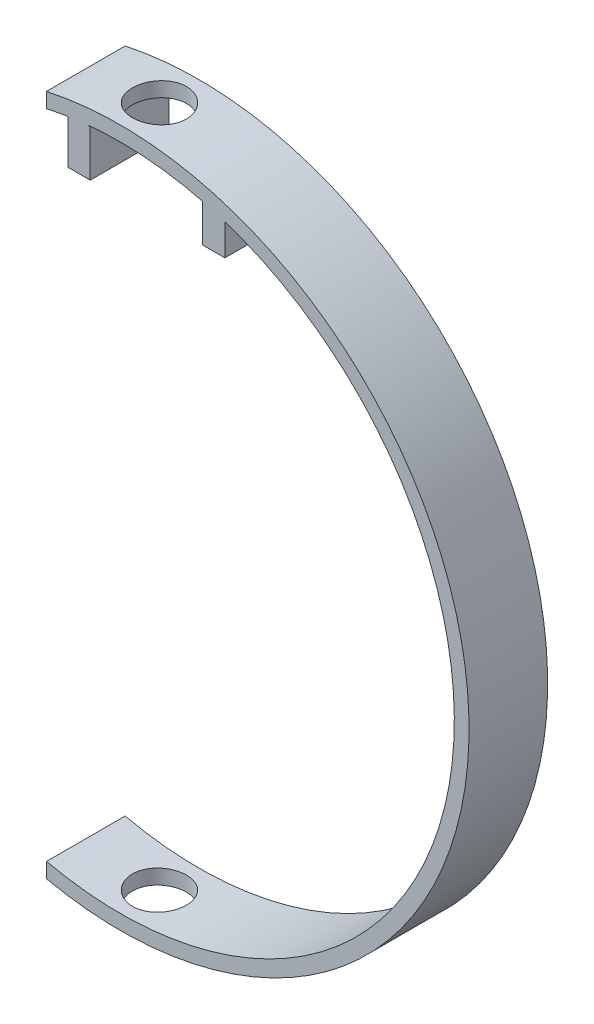
from build123d import *

# Parameters (mm, degrees)
BOSS_EXTRUDE1_DEPTH = 16
SKETCH2_R           = 5.5
CUT_EXTRUDE1_DEPTH  = 143
SKETCH3_W           = 4.5
SKETCH3_H           = 9.432893418
SKETCH3_H_2         = 7.692032902
BOSS_EXTRUDE2_DEPTH = 16
SKETCH4_R           = 0.9
CUT_EXTRUDE2_DEPTH  = 8


with BuildPart() as part:
    # Sketch1 → Boss-Extrude1 (new body)
    with BuildSketch(Plane.XY):
        with BuildLine():
            Line((-15, 140.397406292), (-15, 137.324957595))
            ThreePointArc((-15, 137.324957595), (68, 71), (-15, 4.675042405))
            Line((-15, 4.675042405), (-15, 1.602593708))
            ThreePointArc((-15, 1.602593708), (71, 71), (-15, 140.397406292))
        make_face()
    extrude(amount=BOSS_EXTRUDE1_DEPTH)

    # Sketch2 → Cut-Extrude1 (cut, through all)
    with BuildSketch(Plane(origin=(0, 0, 0), x_dir=(1, 0, 0), z_dir=(0, 1, 0))):
        with Locations((0, -8)):
            Circle(SKETCH2_R)
    extrude(amount=CUT_EXTRUDE1_DEPTH, mode=Mode.SUBTRACT)

    # Sketch3 → Boss-Extrude2 (add)
    with BuildSketch(Plane.XY.offset(16)):
        with Locations((-8.35, 133.916446709)):
            Rectangle(SKETCH3_W, SKETCH3_H)
        with Locations((19.05, 133.046016451)):
            Rectangle(SKETCH3_W, SKETCH3_H_2)
    extrude(amount=-BOSS_EXTRUDE2_DEPTH)

    # Sketch4 → Cut-Extrude2 (cut)
    with BuildSketch(Plane.XZ.offset(-129.2)):
        with Locations((19, 8)):
            Circle(SKETCH4_R)
        with Locations((-8.3, 8)):
            Circle(SKETCH4_R)
    extrude(amount=-CUT_EXTRUDE2_DEPTH, mode=Mode.SUBTRACT)


solid = part.part
